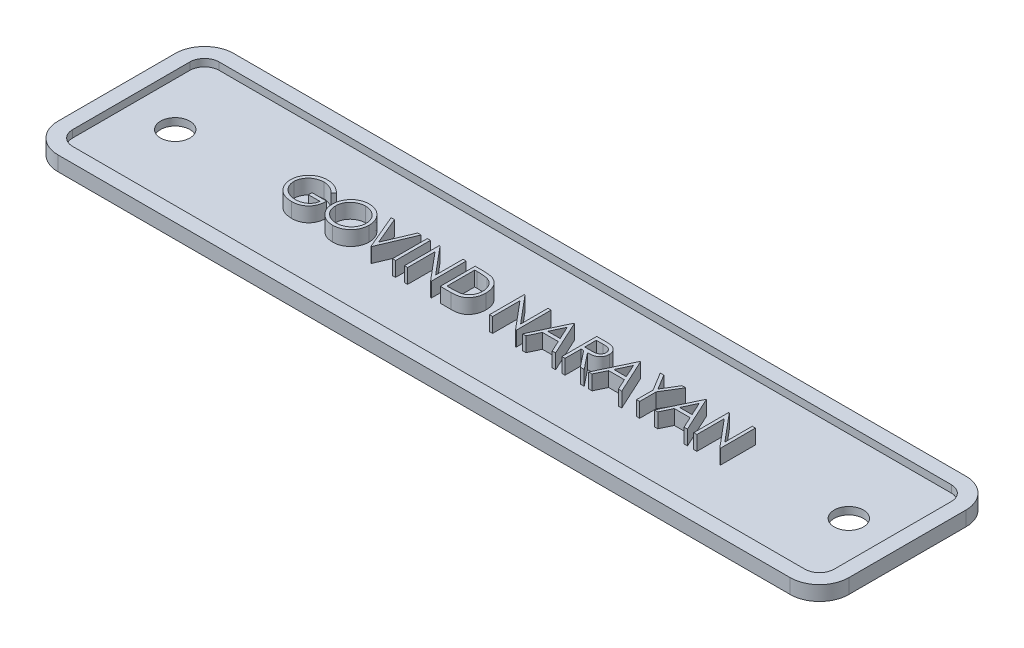
from build123d import *

# Parameters (mm, degrees)
SKETCH1_R           = 1
BOSS_EXTRUDE1_DEPTH = 0.5
BOSS_EXTRUDE2_DEPTH = 1
SKETCH2_W           = 0.213701923
SKETCH2_H           = 2.38125
BOSS_EXTRUDE3_DEPTH = 1


with BuildPart() as part:
    # Sketch1 → Boss-Extrude1 (new body)
    with BuildSketch(Plane(origin=(0, 0, 0), x_dir=(1, 0, 0), z_dir=(0, 1, 0))):
        with BuildLine():
            ThreePointArc((-26, -4), (-25.707106781, -4.707106781), (-25, -5))
            Line((-25, -5), (25, -5))
            ThreePointArc((25, -5), (25.707106781, -4.707106781), (26, -4))
            Line((26, -4), (26, 4))
            ThreePointArc((26, 4), (25.707106781, 4.707106781), (25, 5))
            Line((25, 5), (-25, 5))
            ThreePointArc((-25, 5), (-25.707106781, 4.707106781), (-26, 4))
            Line((-26, 4), (-26, -4))
        make_face()
        with Locations((-23, 0)):
            Circle(SKETCH1_R, mode=Mode.SUBTRACT)
        with Locations((23, 0)):
            Circle(SKETCH1_R, mode=Mode.SUBTRACT)
    extrude(amount=BOSS_EXTRUDE1_DEPTH)

    # Sketch1_3 → Boss-Extrude2 (add)
    with BuildSketch(Plane(origin=(0, 0, 0), x_dir=(1, 0, 0), z_dir=(0, 1, 0))):
        with BuildLine():
            Line((25, 6), (-25, 6))
            ThreePointArc((-25, 6), (-26.414213562, 5.414213562), (-27, 4))
            Line((-27, 4), (-27, -4))
            ThreePointArc((-27, -4), (-26.414213562, -5.414213562), (-25, -6))
            Line((-25, -6), (25, -6))
            ThreePointArc((25, -6), (26.414213562, -5.414213562), (27, -4))
            Line((27, -4), (27, 4))
            ThreePointArc((27, 4), (26.414213562, 5.414213562), (25, 6))
        make_face()
        with BuildLine():
            Line((25, -5), (-25, -5))
            ThreePointArc((-25, -5), (-25.707106781, -4.707106781), (-26, -4))
            Line((-26, -4), (-26, 4))
            ThreePointArc((-26, 4), (-25.707106781, 4.707106781), (-25, 5))
            Line((-25, 5), (25, 5))
            ThreePointArc((25, 5), (25.707106781, 4.707106781), (26, 4))
            Line((26, 4), (26, -4))
            ThreePointArc((26, -4), (25.707106781, -4.707106781), (25, -5))
        make_face(mode=Mode.SUBTRACT)
    extrude(amount=BOSS_EXTRUDE2_DEPTH)

    # Sketch2 → Boss-Extrude3 (add)
    # profile 1 of 13: a face of its own
    with BuildSketch(Plane(origin=(0, 0.5, 0), x_dir=(1, 0, 0), z_dir=(0, 1, 0))):
        with BuildLine():
            Line((-12.744599319, 0.754266948), (-12.927772396, 0.580634136))
            add(Edge.make_bspline(
                [(-12.927772396, 0.580634136), (-12.96091864, 0.611815491), (-13.026420735, 0.673434664), (-13.133209758, 0.753384109), (-13.244627516, 0.821873009), (-13.360092625, 0.877598502), (-13.476745677, 0.922061719), (-13.593038291, 0.953717472), (-13.707777599, 0.973905395), (-13.784091367, 0.976319553), (-13.821695172, 0.977509136)],
                knots=[0, 0, 0, 0, 1.08915593, 2.152340314, 3.188132944, 4.216796309, 5.218260357, 6.173443236, 7.099959455, 8, 8, 8, 8], degree=3))
            add(Edge.make_bspline(
                [(-13.821695172, 0.977509136), (-13.844769281, 0.977227736), (-13.890857654, 0.976665667), (-13.959316512, 0.969491834), (-14.027057385, 0.959174311), (-14.093952395, 0.944245998), (-14.16013161, 0.925325905), (-14.22536486, 0.901659367), (-14.289773831, 0.874067317), (-14.352751826, 0.842184098), (-14.413807418, 0.807159417), (-14.471472337, 0.768346035), (-14.526114131, 0.726987947), (-14.576705778, 0.682049692), (-14.623538289, 0.633938328), (-14.667726378, 0.583548829), (-14.707715931, 0.52950451), (-14.743836884, 0.472799718), (-14.776059699, 0.41443039), (-14.804504515, 0.354958338), (-14.82838307, 0.294580822), (-14.847276217, 0.23322208), (-14.862863644, 0.171356804), (-14.873829373, 0.108556628), (-14.88001159, 0.04475431), (-14.881080962, 0.002029747), (-14.88161855, -0.019448496)],
                knots=[0, 0, 0, 0, 1.02818874, 2.053710826, 3.065248034, 4.081641283, 5.106893873, 6.131558223, 7.173050175, 8.228653731, 9.27666206, 10.308777013, 11.325269123, 12.329503258, 13.32196095, 14.316845687, 15.314881793, 16.315733098, 17.311955233, 18.285320748, 19.252783886, 20.203351036, 21.145449891, 22.095197417, 23.042428769, 24, 24, 24, 24], degree=3))
            add(Edge.make_bspline(
                [(-14.88161855, -0.019448496), (-14.881104392, -0.041404177), (-14.880077479, -0.085255586), (-14.873505011, -0.15070191), (-14.861307405, -0.215176228), (-14.845000803, -0.278890405), (-14.824603141, -0.341953557), (-14.799176381, -0.404092283), (-14.769059963, -0.465304281), (-14.734200809, -0.525038017), (-14.695974124, -0.583224217), (-14.653150349, -0.638033463), (-14.607661274, -0.690195613), (-14.557849674, -0.738552517), (-14.505312807, -0.784397632), (-14.448481026, -0.826467871), (-14.388471852, -0.865573591), (-14.325193731, -0.901221937), (-14.259333267, -0.933068458), (-14.191803226, -0.961387573), (-14.122387873, -0.984709765), (-14.051452007, -1.003717654), (-13.979080192, -1.019298035), (-13.904905069, -1.029321383), (-13.82947203, -1.036594966), (-13.778623068, -1.037126781), (-13.753005269, -1.03739471)],
                knots=[0, 0, 0, 0, 0.93586088, 1.869166235, 2.799637598, 3.729985548, 4.670839027, 5.622275134, 6.589130586, 7.576015415, 8.568469353, 9.55398029, 10.53834874, 11.515998671, 12.510579167, 13.508179873, 14.527009472, 15.561807829, 16.601455013, 17.643573243, 18.680854198, 19.719860599, 20.772568776, 21.833555941, 22.908541556, 24, 24, 24, 24], degree=3))
            add(Edge.make_bspline(
                [(-13.753005269, -1.03739471), (-13.722131786, -1.03674934), (-13.661506687, -1.035482049), (-13.572389125, -1.025616674), (-13.486798107, -1.010208766), (-13.404974137, -0.987644111), (-13.326822178, -0.958862504), (-13.25205573, -0.924167429), (-13.181263441, -0.882228133), (-13.114232496, -0.834893056), (-13.052485197, -0.782155286), (-12.996795159, -0.725247183), (-12.948050639, -0.664444981), (-12.90552512, -0.600106793), (-12.870344768, -0.531700076), (-12.841468509, -0.459560065), (-12.819334251, -0.383654311), (-12.810248099, -0.331204469), (-12.805657011, -0.304702403)],
                knots=[0, 0, 0, 0, 1.13008108, 2.219097802, 3.278683437, 4.311054135, 5.322181354, 6.324827112, 7.324222904, 8.330512327, 9.32562643, 10.293043162, 11.24128371, 12.174520618, 13.111833804, 14.052305215, 15.015860969, 16, 16, 16, 16], degree=3))
            Line((-12.805657011, -0.304702403), (-13.599407011, -0.304702403))
            Line((-13.599407011, -0.304702403), (-13.599407011, -0.060471633))
            Line((-13.599407011, -0.060471633), (-12.591955088, -0.060471633))
            add(Edge.make_bspline(
                [(-12.591955088, -0.060471633), (-12.593115674, -0.105992621), (-12.595387151, -0.195085418), (-12.611320378, -0.325013405), (-12.637049112, -0.447730575), (-12.672196574, -0.563366165), (-12.717695649, -0.671756306), (-12.77305803, -0.773011047), (-12.839169776, -0.866476253), (-12.913675987, -0.95291495), (-12.997291852, -1.030019289), (-13.087758002, -1.0977869), (-13.185223904, -1.154870644), (-13.289597362, -1.201312273), (-13.400536693, -1.237557616), (-13.518298608, -1.263255778), (-13.642723411, -1.278652236), (-13.727997115, -1.280619406), (-13.771608784, -1.281625479)],
                knots=[0, 0, 0, 0, 1.140356446, 2.231883559, 3.274166699, 4.278491846, 5.25512956, 6.21435461, 7.1637429, 8.11826594, 9.068280886, 10.0076534, 10.945064095, 11.891975133, 12.864533718, 13.863980011, 14.907571808, 16, 16, 16, 16], degree=3))
            add(Edge.make_bspline(
                [(-13.771608784, -1.281625479), (-13.798489787, -1.281238274), (-13.851507788, -1.280474579), (-13.929810723, -1.275047134), (-14.005954676, -1.266691956), (-14.079928553, -1.254074649), (-14.152004461, -1.238620572), (-14.221822429, -1.218831215), (-14.289648417, -1.195924475), (-14.355587261, -1.16986974), (-14.419040462, -1.139681166), (-14.480290646, -1.106133001), (-14.539676385, -1.069398232), (-14.59679316, -1.028841568), (-14.65193857, -0.984766358), (-14.704757038, -0.937084263), (-14.755544255, -0.885941055), (-14.78735807, -0.849624264), (-14.803388382, -0.831324999)],
                knots=[0, 0, 0, 0, 1.107784379, 2.184907829, 3.233506516, 4.263428166, 5.276301166, 6.270063455, 7.25232949, 8.225834625, 9.190232166, 10.146266622, 11.1027726, 12.066435141, 13.031522626, 14.010570082, 14.99756817, 16, 16, 16, 16], degree=3))
            add(Edge.make_bspline(
                [(-14.803388382, -0.831324999), (-14.826647025, -0.802293715), (-14.872778241, -0.744713037), (-14.932158558, -0.652456647), (-14.982778084, -0.556933238), (-15.023849763, -0.457876893), (-15.055920497, -0.355380264), (-15.078920822, -0.249574325), (-15.092396853, -0.140322826), (-15.094338278, -0.066391637), (-15.095320473, -0.028988761)],
                knots=[0, 0, 0, 0, 1.023165419, 2.029347347, 3.013907458, 3.994755782, 4.975994455, 5.96558838, 6.970761222, 8, 8, 8, 8], degree=3))
            add(Edge.make_bspline(
                [(-15.095320473, -0.028988761), (-15.094958361, -0.000981007), (-15.094238739, 0.05467854), (-15.085512808, 0.137312887), (-15.072993271, 0.218479965), (-15.054591615, 0.298113425), (-15.031393977, 0.376266453), (-15.002442409, 0.452975336), (-14.968734185, 0.528285341), (-14.929555482, 0.601678098), (-14.885955162, 0.672179707), (-14.838636173, 0.739506355), (-14.78692658, 0.802431951), (-14.731670831, 0.861753412), (-14.672209665, 0.916725485), (-14.609100128, 0.967857121), (-14.542293586, 1.015216908), (-14.471579863, 1.058058885), (-14.398014421, 1.096542348), (-14.321773599, 1.130280722), (-14.24288067, 1.158164014), (-14.161926689, 1.181822603), (-14.07829889, 1.199318083), (-13.992604141, 1.21200589), (-13.904395761, 1.220687655), (-13.844771962, 1.221385876), (-13.814539974, 1.221739905)],
                knots=[0, 0, 0, 0, 1.008945113, 2.00506715, 2.99143336, 3.967273523, 4.948097931, 5.927297278, 6.919902385, 7.919676788, 8.923139349, 9.905703106, 10.883022732, 11.856032218, 12.825136022, 13.798837087, 14.781400844, 15.773989409, 16.776158564, 17.77167057, 18.775803737, 19.789618931, 20.80898985, 21.851988756, 22.910860228, 24, 24, 24, 24], degree=3))
            add(Edge.make_bspline(
                [(-13.814539974, 1.221739905), (-13.789885026, 1.221345644), (-13.740997162, 1.22056387), (-13.668249476, 1.215145065), (-13.596626229, 1.206556317), (-13.52602122, 1.19483595), (-13.456674889, 1.17887226), (-13.388389684, 1.159768999), (-13.321066619, 1.137526884), (-13.254916686, 1.111000544), (-13.189495097, 1.080892274), (-13.124438094, 1.047001356), (-13.059967965, 1.008748273), (-12.995972904, 0.966019439), (-12.932049365, 0.91954872), (-12.869208421, 0.868007024), (-12.805933203, 0.813426899), (-12.765246612, 0.774182413), (-12.744599319, 0.754266948)],
                knots=[0, 0, 0, 0, 0.985871117, 1.954866573, 2.915460327, 3.869826059, 4.81536089, 5.759505086, 6.70452669, 7.649098992, 8.607881297, 9.583363685, 10.581137262, 11.603961102, 12.659522466, 13.73993555, 14.853081303, 16, 16, 16, 16], degree=3))
        make_face()
    # profile 2 of 13: a face of its own
    with BuildSketch(Plane(origin=(0, 0.5, 0), x_dir=(1, 0, 0), z_dir=(0, 1, 0))):
        with BuildLine():
            add(Edge.make_bspline(
                [(-10.989190665, 1.221739905), (-10.945098007, 1.220623113), (-10.85849639, 1.218429641), (-10.731218647, 1.201639037), (-10.609710198, 1.172590923), (-10.492981229, 1.133903787), (-10.382427971, 1.082295714), (-10.277218296, 1.019917068), (-10.17760253, 0.946114335), (-10.08492334, 0.861458021), (-10.000112094, 0.769348922), (-9.925391268, 0.671052343), (-9.862769636, 0.567162623), (-9.811344306, 0.45799195), (-9.771000073, 0.343787222), (-9.743160509, 0.223939588), (-9.725377232, 0.099225572), (-9.723298212, 0.014162652), (-9.72224355, -0.028988761)],
                knots=[0, 0, 0, 0, 1.065120563, 2.091984664, 3.0946048, 4.079830382, 5.057816894, 6.036188127, 7.030412546, 8.04752943, 9.064399622, 10.05169764, 11.02544977, 11.989514704, 12.962713494, 13.945757189, 14.957906945, 16, 16, 16, 16], degree=3))
            add(Edge.make_bspline(
                [(-9.72224355, -0.028988761), (-9.723298058, -0.071822309), (-9.725376614, -0.156252195), (-9.743180729, -0.280174788), (-9.771103266, -0.399298994), (-9.810969655, -0.513425947), (-9.862149846, -0.62267604), (-9.925188454, -0.726761807), (-9.999443456, -0.825717371), (-10.083948474, -0.918458666), (-10.176069541, -1.003501588), (-10.27487799, -1.077605323), (-10.378151659, -1.141371201), (-10.487219514, -1.192250808), (-10.600635075, -1.232917061), (-10.719413406, -1.260643404), (-10.842997936, -1.278527981), (-10.927274458, -1.28058165), (-10.970110136, -1.281625479)],
                knots=[0, 0, 0, 0, 1.043624062, 2.057103931, 3.04512605, 4.022047818, 4.998200453, 5.980619268, 6.982898556, 8.009068085, 9.034988726, 10.034168286, 11.015286542, 11.987931943, 12.962482838, 13.94673481, 14.956375938, 16, 16, 16, 16], degree=3))
            add(Edge.make_bspline(
                [(-10.970110136, -1.281625479), (-11.013261325, -1.280571343), (-11.098323804, -1.27849336), (-11.223194537, -1.260680654), (-11.343126359, -1.232825945), (-11.457776302, -1.193018632), (-11.567208298, -1.141571909), (-11.671636372, -1.078840002), (-11.770641364, -1.004404072), (-11.863402445, -0.919926456), (-11.948276453, -0.827961525), (-12.022271671, -0.729422505), (-12.085017686, -0.626242632), (-12.136291667, -0.518135566), (-12.176884808, -0.405623924), (-12.204578622, -0.287957192), (-12.222496475, -0.165806207), (-12.224561255, -0.082637378), (-12.225608934, -0.040437078)],
                knots=[0, 0, 0, 0, 1.053102029, 2.075944431, 3.073151272, 4.055350789, 5.033113405, 6.020478099, 7.024410459, 8.052272461, 9.079885166, 10.07527673, 11.055994387, 12.023226415, 12.992069828, 13.970394897, 14.97016774, 16, 16, 16, 16], degree=3))
            add(Edge.make_bspline(
                [(-12.225608934, -0.040437078), (-12.225245191, -0.012111994), (-12.224522294, 0.04418084), (-12.215819375, 0.127774009), (-12.203190789, 0.210022831), (-12.185091987, 0.290693423), (-12.161421228, 0.369588307), (-12.133491188, 0.447251594), (-12.099378186, 0.522896234), (-12.060815103, 0.596880578), (-12.01777448, 0.668051314), (-11.970234014, 0.735324744), (-11.919863523, 0.799265387), (-11.864643428, 0.858216295), (-11.806393668, 0.913892407), (-11.744169307, 0.965438113), (-11.67835003, 1.013318214), (-11.608652625, 1.056466696), (-11.536794478, 1.095491393), (-11.462719384, 1.128979831), (-11.387433395, 1.15772224), (-11.310583894, 1.18101823), (-11.232374954, 1.199409669), (-11.152635883, 1.211933244), (-11.071430205, 1.22065836), (-11.01672179, 1.221377839), (-10.989190665, 1.221739905)],
                knots=[0, 0, 0, 0, 1.037015668, 2.060948919, 3.074880161, 4.083647147, 5.086022904, 6.090072063, 7.104153813, 8.122640571, 9.144368836, 10.147691507, 11.138137339, 12.123020368, 13.103399296, 14.087645067, 15.080126199, 16.082011238, 17.087798457, 18.072939717, 19.057185487, 20.037253025, 21.01195951, 21.997135196, 22.992090687, 24, 24, 24, 24], degree=3))
        make_face()
        with BuildLine():
            add(Edge.make_bspline(
                [(-10.978696374, 0.977509136), (-11.001294188, 0.977233666), (-11.046273777, 0.97668536), (-11.113142364, 0.969462882), (-11.179131519, 0.959169154), (-11.24425487, 0.944486012), (-11.308239935, 0.924480754), (-11.371683131, 0.901456851), (-11.434005923, 0.873411787), (-11.495002565, 0.841725715), (-11.554135857, 0.806654039), (-11.609933785, 0.76789289), (-11.662540798, 0.726351267), (-11.711828092, 0.68193222), (-11.757650943, 0.634409545), (-11.800911248, 0.584503691), (-11.839875017, 0.530788208), (-11.875583955, 0.474719699), (-11.90753886, 0.416371194), (-11.935954218, 0.356356985), (-11.959197945, 0.294187523), (-11.978154312, 0.230537283), (-11.993870433, 0.165507074), (-12.003826728, 0.098603577), (-12.011128565, 0.030162974), (-12.011645531, -0.016088966), (-12.011907011, -0.039483052)],
                knots=[0, 0, 0, 0, 1.008559885, 2.007477868, 2.99961109, 3.989939068, 4.984837346, 5.991145699, 7.001802488, 8.033829008, 9.059044045, 10.069351652, 11.065060232, 12.050310815, 13.029377138, 14.011219647, 14.996725999, 15.989392538, 16.977580475, 17.965360261, 18.951710183, 19.937753436, 20.929683414, 21.935841486, 22.955955122, 24, 24, 24, 24], degree=3))
            add(Edge.make_bspline(
                [(-12.011907011, -0.039483052), (-12.01103965, -0.07388342), (-12.009333282, -0.141559586), (-11.994394292, -0.240733984), (-11.97138327, -0.33604405), (-11.937462455, -0.426968277), (-11.895041769, -0.514288227), (-11.842635974, -0.597229277), (-11.780547203, -0.675813843), (-11.710018982, -0.749493303), (-11.632919069, -0.816743752), (-11.551049837, -0.875773857), (-11.465288365, -0.925719045), (-11.375411007, -0.966407853), (-11.281897592, -0.998649799), (-11.184145544, -1.020746868), (-11.082806035, -1.035289812), (-11.013728929, -1.036686419), (-10.978696374, -1.03739471)],
                knots=[0, 0, 0, 0, 1.032063989, 2.030389145, 3.003944642, 3.970395727, 4.937377036, 5.913328081, 6.909231446, 7.93887556, 8.970685674, 9.976071282, 10.964166581, 11.944589148, 12.933237628, 13.927779006, 14.949070134, 16, 16, 16, 16], degree=3))
            add(Edge.make_bspline(
                [(-10.978696374, -1.03739471), (-10.955149553, -1.037071197), (-10.908449133, -1.036429574), (-10.838987715, -1.029967082), (-10.770777686, -1.019603971), (-10.703914717, -1.004683292), (-10.638474693, -0.986009389), (-10.574184479, -0.963824489), (-10.511728856, -0.936146741), (-10.450319931, -0.905566081), (-10.391539631, -0.870704474), (-10.335426813, -0.833258876), (-10.283395834, -0.791778439), (-10.234145412, -0.748019356), (-10.188134431, -0.70109931), (-10.145674033, -0.651079302), (-10.106907193, -0.597643605), (-10.071211816, -0.541660141), (-10.039368882, -0.483151976), (-10.01162453, -0.422920177), (-9.988086816, -0.361113058), (-9.969085458, -0.297641471), (-9.954195528, -0.232625965), (-9.943935797, -0.165979487), (-9.936759091, -0.097835363), (-9.936218155, -0.051745347), (-9.935945473, -0.028511747)],
                knots=[0, 0, 0, 0, 1.047197238, 2.076906641, 3.100256066, 4.114471768, 5.12198147, 6.126382909, 7.136867548, 8.15857795, 9.17633901, 10.174870724, 11.156907918, 12.133735059, 13.104061851, 14.077631395, 15.04955518, 16.038496417, 17.029181396, 18.010275684, 18.986308667, 19.968651475, 20.955262928, 21.950658345, 22.966943676, 24, 24, 24, 24], degree=3))
            add(Edge.make_bspline(
                [(-9.935945473, -0.028511747), (-9.936218373, -0.005437092), (-9.936759721, 0.040335738), (-9.943932368, 0.108004616), (-9.954206367, 0.174171533), (-9.969012781, 0.238576728), (-9.988096903, 0.301236617), (-10.011628641, 0.362092351), (-10.039377211, 0.421370641), (-10.07122352, 0.478924975), (-10.107021072, 0.534152788), (-10.146137691, 0.586950143), (-10.189248758, 0.636325526), (-10.235122536, 0.683497881), (-10.28490487, 0.727461123), (-10.338370256, 0.768229838), (-10.394869615, 0.806787905), (-10.454691538, 0.841571547), (-10.516429835, 0.873694087), (-10.579780581, 0.901215216), (-10.644026094, 0.924600533), (-10.709002999, 0.944546539), (-10.775258204, 0.959111646), (-10.842344023, 0.969472158), (-10.910167642, 0.976682846), (-10.955780975, 0.977232832), (-10.978696374, 0.977509136)],
                knots=[0, 0, 0, 0, 1.02996197, 2.043119294, 3.035359645, 4.018872909, 4.991431989, 5.957985074, 6.929999688, 7.912076566, 8.892894881, 9.867085534, 10.843653904, 11.817741046, 12.803660682, 13.806313499, 14.818574707, 15.856120519, 16.894564902, 17.924820532, 18.937903209, 19.946497019, 20.957711757, 21.963978472, 22.977135795, 24, 24, 24, 24], degree=3))
        make_face(mode=Mode.SUBTRACT)
    # profile 3 of 13: a face of its own
    with BuildSketch(Plane(origin=(0, 0.5, 0), x_dir=(1, 0, 0), z_dir=(0, 1, 0))):
        Polygon((-9.416955088, 1.160682213), (-9.187988742, 1.160682213), (-8.394238742, -0.715887799), (-7.600488742, 1.160682213), (-7.371522396, 1.160682213), (-8.378974319, -1.220567787), (-8.409503165, -1.220567787), align=None)
    # profile 4 of 13: a face of its own
    with BuildSketch(Plane(origin=(0, 0.5, 0), x_dir=(1, 0, 0), z_dir=(0, 1, 0))):
        with Locations((-6.837267589, -0.029942787)):
            Rectangle(SKETCH2_W, SKETCH2_H)
    # profile 5 of 13: a face of its own
    with BuildSketch(Plane(origin=(0, 0.5, 0), x_dir=(1, 0, 0), z_dir=(0, 1, 0))):
        Polygon((-6.119839704, -1.220567787), (-6.119839704, 1.160682213), (-6.075000461, 1.160682213), (-4.501810858, -0.713502733), (-4.501810858, 1.160682213), (-4.288108934, 1.160682213), (-4.288108934, -1.220567787), (-4.336764283, -1.220567787), (-5.906137781, 0.64932404), (-5.906137781, -1.220567787), align=None)
    # profile 6 of 13: a face of its own
    with BuildSketch(Plane(origin=(0, 0.5, 0), x_dir=(1, 0, 0), z_dir=(0, 1, 0))):
        with BuildLine():
            Line((-3.677532011, -1.220567787), (-3.677532011, 1.160682213))
            Line((-3.677532011, 1.160682213), (-3.196702684, 1.160682213))
            add(Edge.make_bspline(
                [(-3.196702684, 1.160682213), (-3.154881819, 1.160381107), (-3.074084125, 1.159799373), (-2.957326371, 1.15611089), (-2.849296704, 1.149585948), (-2.750350419, 1.140081682), (-2.660215881, 1.128411493), (-2.57914547, 1.113783539), (-2.506719995, 1.096510516), (-2.462177393, 1.081783879), (-2.441113742, 1.074819833)],
                knots=[0, 0, 0, 0, 1.314313732, 2.53924729, 3.670748893, 4.714932338, 5.66265055, 6.526160246, 7.303039223, 8, 8, 8, 8], degree=3))
            add(Edge.make_bspline(
                [(-2.441113742, 1.074819833), (-2.413562857, 1.064321442), (-2.359085849, 1.043562729), (-2.281520289, 1.004403889), (-2.208500712, 0.960035689), (-2.139635544, 0.910399647), (-2.076497839, 0.854090331), (-2.016621037, 0.793499707), (-1.962454591, 0.726424425), (-1.912850911, 0.654255549), (-1.868127186, 0.577843243), (-1.829252152, 0.497333106), (-1.796966488, 0.413134006), (-1.770165025, 0.325480092), (-1.749042346, 0.234178628), (-1.734631068, 0.139123301), (-1.725125805, 0.040689782), (-1.724170549, -0.026103916), (-1.723685858, -0.05999462)],
                knots=[0, 0, 0, 0, 0.984719456, 1.947108742, 2.898477687, 3.838006223, 4.779231079, 5.722358779, 6.681677486, 7.655904652, 8.64651281, 9.637519902, 10.640069247, 11.656948941, 12.698408672, 13.768548281, 14.867775369, 16, 16, 16, 16], degree=3))
            add(Edge.make_bspline(
                [(-1.723685858, -0.05999462), (-1.72411378, -0.089427713), (-1.724957046, -0.147428696), (-1.732528956, -0.232909377), (-1.743534631, -0.315854146), (-1.760573629, -0.395868024), (-1.781258197, -0.473652043), (-1.807767735, -0.548377195), (-1.838135814, -0.620728966), (-1.873548321, -0.68972907), (-1.91242487, -0.755100079), (-1.954145556, -0.816723786), (-1.998665879, -0.873720857), (-2.046410372, -0.926263894), (-2.096762051, -0.97427369), (-2.150050568, -1.018151293), (-2.20641343, -1.057038163), (-2.265598189, -1.092462392), (-2.329331413, -1.123364456), (-2.398820279, -1.149510587), (-2.474361134, -1.17117766), (-2.555768558, -1.189255358), (-2.64318321, -1.203595452), (-2.736690792, -1.213206444), (-2.836147638, -1.21970585), (-2.904441388, -1.220274896), (-2.939592558, -1.220567787)],
                knots=[0, 0, 0, 0, 1.105936401, 2.179363191, 3.223086493, 4.248585256, 5.251745608, 6.245858792, 7.225916811, 8.198733463, 9.158002045, 10.082870192, 10.993790845, 11.873723703, 12.748670949, 13.606408763, 14.465103618, 15.319838547, 16.196477973, 17.123216899, 18.106603292, 19.147568657, 20.255746949, 21.433717677, 22.679120308, 24, 24, 24, 24], degree=3))
            Line((-2.939592558, -1.220567787), (-3.677532011, -1.220567787))
        make_face()
        with BuildLine():
            Line((-3.463830088, -0.976337018), (-3.190501513, -0.976337018))
            add(Edge.make_bspline(
                [(-3.190501513, -0.976337018), (-3.151225603, -0.976168224), (-3.075683646, -0.975843571), (-2.967059187, -0.972994777), (-2.867809097, -0.968339816), (-2.777919285, -0.961825344), (-2.697440502, -0.953206161), (-2.626204558, -0.943596182), (-2.564444963, -0.931623631), (-2.527073328, -0.920771282), (-2.509803646, -0.915756339)],
                knots=[0, 0, 0, 0, 1.375205317, 2.645023457, 3.804390687, 4.853969522, 5.800190428, 6.637939096, 7.370582563, 8, 8, 8, 8], degree=3))
            add(Edge.make_bspline(
                [(-2.509803646, -0.915756339), (-2.48806735, -0.908101261), (-2.445113928, -0.892973946), (-2.383282332, -0.865380252), (-2.325617299, -0.832694486), (-2.271113871, -0.796361868), (-2.2205452, -0.755100927), (-2.173312007, -0.709808879), (-2.129509388, -0.66025522), (-2.089589904, -0.606501453), (-2.053865504, -0.548882145), (-2.022928828, -0.48796376), (-1.995815554, -0.42441377), (-1.97453494, -0.357256289), (-1.957855587, -0.287091697), (-1.946041398, -0.213915059), (-1.938683523, -0.137740041), (-1.937825288, -0.085929399), (-1.937387781, -0.059517607)],
                knots=[0, 0, 0, 0, 0.998632004, 1.973411704, 2.929992603, 3.868527914, 4.809262121, 5.754881198, 6.702106254, 7.672490631, 8.653608572, 9.636854334, 10.631411391, 11.644891563, 12.686317036, 13.754757253, 14.855430412, 16, 16, 16, 16], degree=3))
            add(Edge.make_bspline(
                [(-1.937387781, -0.059517607), (-1.937736999, -0.031668221), (-1.938423043, 0.023042144), (-1.9470461, 0.103317956), (-1.959647373, 0.180525327), (-1.977869845, 0.254669421), (-2.001091032, 0.325894889), (-2.030070601, 0.393807806), (-2.063181283, 0.459125404), (-2.102576232, 0.520340106), (-2.145721484, 0.578233811), (-2.193603577, 0.631270995), (-2.245461785, 0.679572474), (-2.300730495, 0.723890471), (-2.360967343, 0.762442007), (-2.424753336, 0.796927053), (-2.49302423, 0.826193222), (-2.540521797, 0.841759019), (-2.564660166, 0.849669593)],
                knots=[0, 0, 0, 0, 1.122418816, 2.205001699, 3.251619955, 4.274784885, 5.280384055, 6.268708349, 7.249350384, 8.229342522, 9.199999885, 10.157847722, 11.105861043, 12.055065948, 13.010012805, 13.98527497, 14.976112212, 16, 16, 16, 16], degree=3))
            add(Edge.make_bspline(
                [(-2.564660166, 0.849669593), (-2.584629429, 0.855191662), (-2.627089559, 0.866933098), (-2.696376765, 0.879741074), (-2.774356001, 0.891038064), (-2.861373476, 0.900602551), (-2.957329999, 0.907465532), (-3.062299369, 0.91261673), (-3.176326957, 0.916091064), (-3.255372574, 0.91632831), (-3.296398448, 0.916451444)],
                knots=[0, 0, 0, 0, 0.674548936, 1.434276114, 2.292660221, 3.240891867, 4.284742987, 5.42552168, 6.663806718, 8, 8, 8, 8], degree=3))
            Line((-3.296398448, 0.916451444), (-3.463830088, 0.916451444))
            Line((-3.463830088, 0.916451444), (-3.463830088, -0.976337018))
        make_face(mode=Mode.SUBTRACT)
    # profile 7 of 13: a face of its own
    with BuildSketch(Plane(origin=(0, 0.5, 0), x_dir=(1, 0, 0), z_dir=(0, 1, 0))):
        Polygon((-0.319358934, -1.220567787), (-0.319358934, 1.160682213), (-0.274519692, 1.160682213), (1.298669912, -0.713502733), (1.298669912, 1.160682213), (1.512371835, 1.160682213), (1.512371835, -1.220567787), (1.463716486, -1.220567787), (-0.105657011, 0.64932404), (-0.105657011, -1.220567787), align=None)
    # profile 8 of 13: a face of its own
    with BuildSketch(Plane(origin=(0, 0.5, 0), x_dir=(1, 0, 0), z_dir=(0, 1, 0))):
        Polygon((3.099871835, 1.160682213), (4.198910296, -1.220567787), (3.966604858, -1.220567787), (3.6145691, -0.457346633), (2.535088181, -0.457346633), (2.173035146, -1.220567787), (1.939775681, -1.220567787), (3.069342989, 1.160682213), align=None)
        Polygon((3.082222346, 0.696548349), (2.651002394, -0.213115864), (3.50199398, -0.213115864), align=None, mode=Mode.SUBTRACT)
    # profile 9 of 13: a face of its own
    with BuildSketch(Plane(origin=(0, 0.5, 0), x_dir=(1, 0, 0), z_dir=(0, 1, 0))):
        with BuildLine():
            Line((4.626314142, 1.160682213), (5.10285035, 1.160682213))
            add(Edge.make_bspline(
                [(5.10285035, 1.160682213), (5.134651011, 1.160576359), (5.195711802, 1.160373107), (5.283187545, 1.159239794), (5.362671695, 1.155991527), (5.434122693, 1.153196223), (5.497539228, 1.148099027), (5.553115759, 1.143227229), (5.600596318, 1.136849792), (5.629338585, 1.130926996), (5.642352304, 1.128245314)],
                knots=[0, 0, 0, 0, 1.410062039, 2.707475311, 3.878576406, 4.937260626, 5.877586885, 6.699081471, 7.410979367, 8, 8, 8, 8], degree=3))
            add(Edge.make_bspline(
                [(5.642352304, 1.128245314), (5.659773953, 1.123940854), (5.694245601, 1.11542376), (5.7438777, 1.097421781), (5.791172267, 1.076589501), (5.835932844, 1.052121327), (5.87793523, 1.023835629), (5.917612509, 0.99222071), (5.955144726, 0.957449557), (5.989014014, 0.918645495), (6.020949333, 0.877935298), (6.047883738, 0.833913635), (6.071101932, 0.787879632), (6.089587588, 0.739365121), (6.104472423, 0.688840594), (6.114967775, 0.635848395), (6.121261887, 0.580629946), (6.121902685, 0.542966797), (6.122227604, 0.523869563)],
                knots=[0, 0, 0, 0, 1.027469482, 2.033020251, 3.019912614, 3.986113645, 4.951240523, 5.91722682, 6.890402269, 7.87763091, 8.8651537, 9.85103654, 10.82876324, 11.815024772, 12.821070561, 13.842952187, 14.906261191, 16, 16, 16, 16], degree=3))
            add(Edge.make_bspline(
                [(6.122227604, 0.523869563), (6.121228161, 0.492141036), (6.119277988, 0.430230463), (6.101095373, 0.340381899), (6.071311705, 0.256569169), (6.030270324, 0.178897803), (5.978005645, 0.10888181), (5.915191814, 0.047384018), (5.841793789, -0.004078137), (5.773465987, -0.039764777), (5.713108647, -0.062619952), (5.663419911, -0.078701118), (5.609217914, -0.091125776), (5.551021977, -0.102256509), (5.488589919, -0.110660073), (5.422071374, -0.116814988), (5.351418903, -0.12066176), (5.302882858, -0.121234624), (5.277914203, -0.121529326)],
                knots=[0, 0, 0, 0, 1.260483769, 2.459530307, 3.627416485, 4.787058657, 5.939039949, 7.08810263, 8.267026773, 9.491475466, 10.141966685, 10.831826277, 11.566392101, 12.351337768, 13.187381173, 14.07005841, 15.007169909, 16, 16, 16, 16], degree=3))
            Line((5.277914203, -0.121529326), (6.15275645, -1.220567787))
            Line((6.15275645, -1.220567787), (5.888491126, -1.220567787))
            Line((5.888491126, -1.220567787), (5.013648878, -0.121529326))
            Line((5.013648878, -0.121529326), (4.840016066, -0.121529326))
            Line((4.840016066, -0.121529326), (4.840016066, -1.220567787))
            Line((4.840016066, -1.220567787), (4.626314142, -1.220567787))
            Line((4.626314142, -1.220567787), (4.626314142, 1.160682213))
        make_face()
        with BuildLine():
            Line((4.840016066, 0.916451444), (4.840016066, 0.122701444))
            Line((4.840016066, 0.122701444), (5.27600615, 0.119362351))
            add(Edge.make_bspline(
                [(5.27600615, 0.119362351), (5.296362462, 0.119353345), (5.335818793, 0.11933589), (5.392901209, 0.122053084), (5.446050785, 0.125144163), (5.495064226, 0.1298722), (5.539963426, 0.135965527), (5.580725945, 0.143587558), (5.617418321, 0.152467622), (5.660211791, 0.166211942), (5.707997717, 0.187987465), (5.759930371, 0.219668635), (5.804155175, 0.259516554), (5.841518935, 0.305082423), (5.871542709, 0.355181371), (5.892710018, 0.409212865), (5.906141929, 0.465812863), (5.907726172, 0.504714397), (5.908525681, 0.524346576)],
                knots=[0, 0, 0, 0, 1.146690395, 2.22261258, 3.21895312, 4.145990853, 4.996080663, 5.770904154, 6.481378293, 7.121626537, 8.300444488, 9.431385265, 10.535395872, 11.636531494, 12.74115979, 13.810798291, 14.895190096, 16, 16, 16, 16], degree=3))
            add(Edge.make_bspline(
                [(5.908525681, 0.524346576), (5.907707809, 0.543496298), (5.906087086, 0.581444061), (5.892854977, 0.636999243), (5.870478452, 0.689432293), (5.840323501, 0.738529915), (5.80358479, 0.783097211), (5.760506064, 0.821229292), (5.712265208, 0.852695445), (5.667177125, 0.872802979), (5.626876705, 0.885130951), (5.591886169, 0.893806296), (5.55234961, 0.900776194), (5.508075057, 0.906360607), (5.459251518, 0.911160488), (5.405632129, 0.914393395), (5.347572641, 0.916307827), (5.307331604, 0.916402457), (5.286500441, 0.916451444)],
                knots=[0, 0, 0, 0, 1.101028733, 2.181837193, 3.264309656, 4.369019818, 5.486613113, 6.575447106, 7.666700264, 8.788928104, 9.402425223, 10.0903467, 10.862060571, 11.710948788, 12.657782767, 13.684531032, 14.801375019, 16, 16, 16, 16], degree=3))
            Line((5.286500441, 0.916451444), (4.840016066, 0.916451444))
        make_face(mode=Mode.SUBTRACT)
    # profile 10 of 13: a face of its own
    with BuildSketch(Plane(origin=(0, 0.5, 0), x_dir=(1, 0, 0), z_dir=(0, 1, 0))):
        Polygon((7.618141066, 1.160682213), (8.717179527, -1.220567787), (8.484874088, -1.220567787), (8.132838331, -0.457346633), (7.053357412, -0.457346633), (6.691304377, -1.220567787), (6.458044912, -1.220567787), (7.587612219, 1.160682213), align=None)
        Polygon((7.600491576, 0.696548349), (7.169271624, -0.213115864), (8.020263211, -0.213115864), align=None, mode=Mode.SUBTRACT)
    # profile 11 of 13: a face of its own
    with BuildSketch(Plane(origin=(0, 0.5, 0), x_dir=(1, 0, 0), z_dir=(0, 1, 0))):
        Polygon((8.961410296, 1.160682213), (9.206118079, 1.160682213), (9.831959425, 0.137488853), (10.456846745, 1.160682213), (10.701554527, 1.160682213), (9.938333373, -0.088615413), (9.938333373, -1.220567787), (9.72463145, -1.220567787), (9.72463145, -0.088615413), align=None)
    # profile 12 of 13: a face of its own
    with BuildSketch(Plane(origin=(0, 0.5, 0), x_dir=(1, 0, 0), z_dir=(0, 1, 0))):
        Polygon((12.10588145, 1.160682213), (13.204919912, -1.220567787), (12.972614473, -1.220567787), (12.620578716, -0.457346633), (11.541097796, -0.457346633), (11.179044761, -1.220567787), (10.945785296, -1.220567787), (12.075352604, 1.160682213), align=None)
        Polygon((12.088231961, 0.696548349), (11.657012009, -0.213115864), (12.508003596, -0.213115864), align=None, mode=Mode.SUBTRACT)
    # profile 13 of 13: a face of its own
    with BuildSketch(Plane(origin=(0, 0.5, 0), x_dir=(1, 0, 0), z_dir=(0, 1, 0))):
        Polygon((13.632323758, -1.220567787), (13.632323758, 1.160682213), (13.677163001, 1.160682213), (15.250352604, -0.713502733), (15.250352604, 1.160682213), (15.464054527, 1.160682213), (15.464054527, -1.220567787), (15.415399179, -1.220567787), (13.846025681, 0.64932404), (13.846025681, -1.220567787), align=None)
    extrude(amount=BOSS_EXTRUDE3_DEPTH)


solid = part.part
